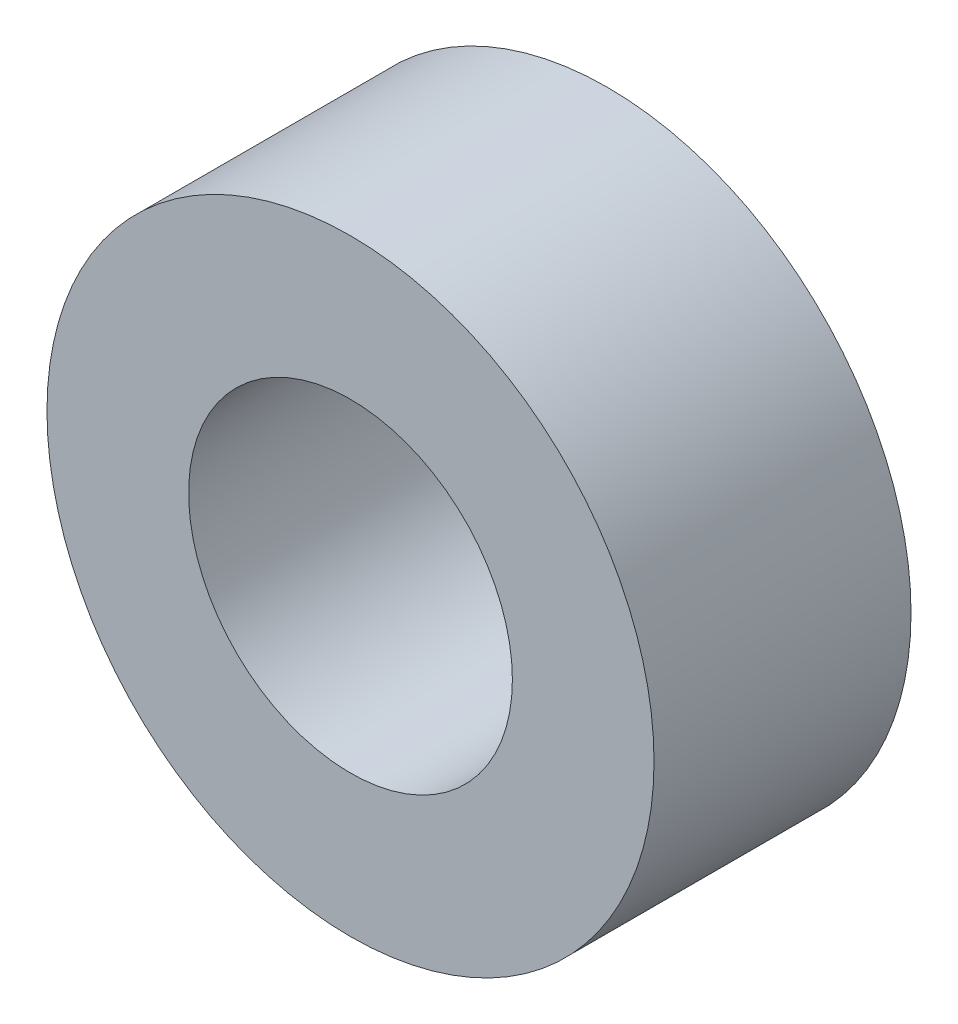
from build123d import *

# Parameters (mm, degrees)
SKETCH1_R           = 3.75
SKETCH1_R_2         = 2
BOSS_EXTRUDE1_DEPTH = 3.175


with BuildPart() as part:
    # Sketch1 → Boss-Extrude1 (new body)
    with BuildSketch(Plane.XY):
        Circle(SKETCH1_R)
        Circle(SKETCH1_R_2, mode=Mode.SUBTRACT)
    extrude(amount=BOSS_EXTRUDE1_DEPTH)


solid = part.part
